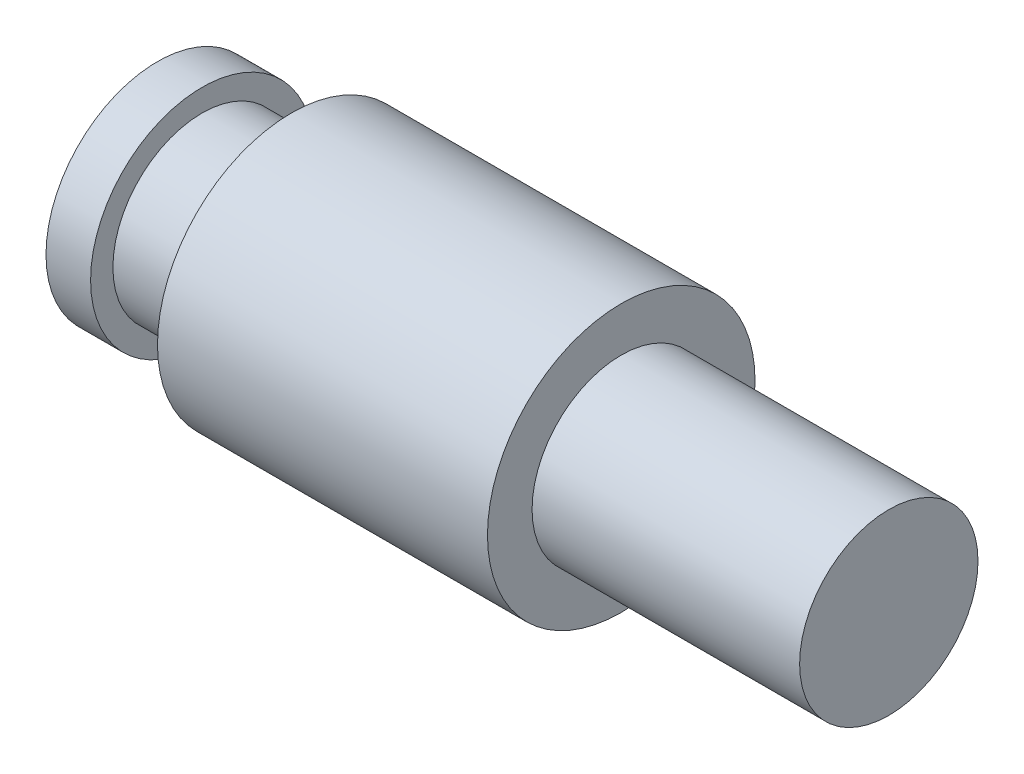
from build123d import *


with BuildPart() as part:
    # Esquisse1 → Révolution1 (revolve)
    with BuildSketch(Plane.XY, mode=Mode.PRIVATE) as r_volution1_sk:
        Polygon((0, 0), (0, 2.5), (1, 2.5), (1, 2), (3, 2), (3, 3), (10.4, 3), (10.4, 2), (16.4, 2), (16.4, 0), align=None)
    revolve(r_volution1_sk.sketch.rotate(Axis((16.4, 0, 0), (-1, 0, 0)), 90), axis=Axis((16.4, 0, 0), (-1, 0, 0)))  # turned: the seam where the file's is


solid = part.part
